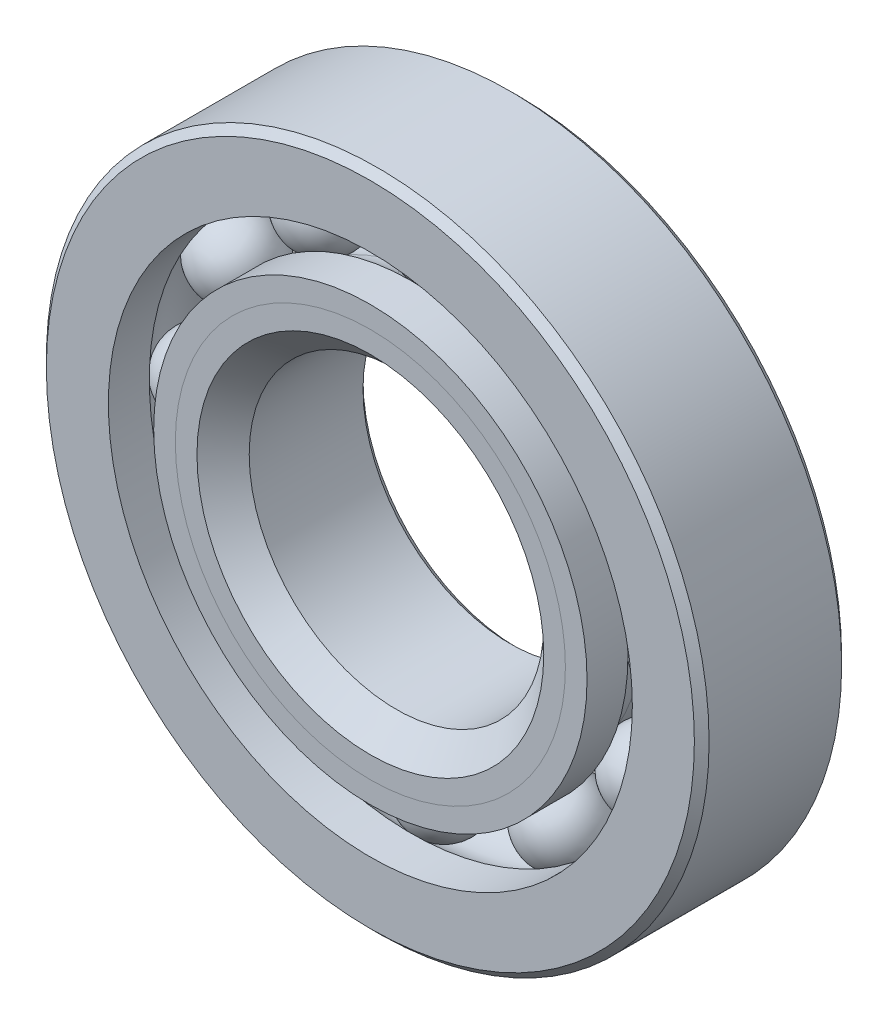
from build123d import *

# Parameters (mm, degrees)
CIRPATTERN1_COUNT = 12


with BuildPart() as part:
    # Sketch1 → Revolve1 (revolve)
    with BuildSketch(Plane(origin=(0, 0, 0), x_dir=(0, 0, -1), z_dir=(1, 0, 0))):
        with BuildLine():
            Line((2.8575, 14.2875), (-2.8575, 14.2875))
            Line((-2.8575, 14.2875), (-3.175, 13.97))
            Line((-3.175, 13.97), (-3.175, 11.295673077))
            Line((-3.175, 11.295673077), (-1.411111111, 11.295673077))
            ThreePointArc((-1.411111111, 11.295673077), (0, 12.035028901), (1.411111111, 11.295673077))
            Line((1.411111111, 11.295673077), (3.175, 11.295673077))
            Line((3.175, 11.295673077), (3.175, 13.97))
            Line((3.175, 13.97), (2.8575, 14.2875))
        make_face()
    revolve(axis=Axis((0, 0, 3.175), (0, 0, -1)))


with BuildPart() as body_2:
    # Sketch2 → Revolve2 (revolve)
    with BuildSketch(Plane(origin=(0, 0, 0), x_dir=(0, 0, -1), z_dir=(1, 0, 0))):
        with BuildLine():
            Line((-3.175, 9.341826923), (-1.411111111, 9.341826923))
            ThreePointArc((-1.411111111, 9.341826923), (-0.796536503, 8.798505656), (0, 8.602471099))
            Line((0, 8.602471099), (0, 7.476235549))
            Line((0, 7.476235549), (-2.242204313, 7.476235549))
            Line((-2.242204313, 7.476235549), (-3.175, 8.409031236))
            Line((-3.175, 8.409031236), (-3.175, 9.341826923))
        make_face()
    revolve(axis=Axis((0, 0, 3.175), (0, 0, -1)))


with BuildPart() as body_3:
    # Sketch3 → Revolve3 (revolve)
    with BuildSketch(Plane(origin=(0, 0, 0), x_dir=(0, 0, -1), z_dir=(1, 0, 0))):
        with BuildLine():
            Line((-3.175, 8.409031236), (-2.242204313, 7.476235549))
            Line((-2.242204313, 7.476235549), (0, 7.476235549))
            Line((0, 7.476235549), (0, 8.602471099))
            ThreePointArc((0, 8.602471099), (0.796536503, 8.798505656), (1.411111111, 9.341826923))
            Line((1.411111111, 9.341826923), (3.175, 9.341826923))
            Line((3.175, 9.341826923), (3.175, 6.6675))
            Line((3.175, 6.6675), (2.8575, 6.35))
            Line((2.8575, 6.35), (-2.048764451, 6.35))
            Line((-2.048764451, 6.35), (-3.175, 7.476235549))
            Line((-3.175, 7.476235549), (-3.175, 8.409031236))
        make_face()
    revolve(axis=Axis((0, 0, 3.175), (0, 0, -1)))


with BuildPart() as body_4:
    # Sketch4 → Revolve4 (revolve)
    with BuildSketch(Plane(origin=(0, 0, 0), x_dir=(0, 0, -1), z_dir=(1, 0, 0))):
        with BuildLine():
            Line((-1.716278901, 10.31875), (1.716278901, 10.31875))
            ThreePointArc((1.716278901, 10.31875), (0, 12.035028901), (-1.716278901, 10.31875))
        make_face()
    revolve(axis=Axis((0, 10.31875, 1.716278901), (0, 0, -1)))


with BuildPart() as cirpattern1_1:
    # CirPattern1: pattern copy
    add(body_4.part.rotate(Axis((0, 0, -3.175), (0, 0, 1)), 1 * 360 / CIRPATTERN1_COUNT))


with BuildPart() as cirpattern1_2:
    # CirPattern1: pattern copy
    add(body_4.part.rotate(Axis((0, 0, -3.175), (0, 0, 1)), 2 * 360 / CIRPATTERN1_COUNT))


with BuildPart() as cirpattern1_3:
    # CirPattern1: pattern copy
    add(body_4.part.rotate(Axis((0, 0, -3.175), (0, 0, 1)), 3 * 360 / CIRPATTERN1_COUNT))


with BuildPart() as cirpattern1_4:
    # CirPattern1: pattern copy
    add(body_4.part.rotate(Axis((0, 0, -3.175), (0, 0, 1)), 4 * 360 / CIRPATTERN1_COUNT))


with BuildPart() as cirpattern1_5:
    # CirPattern1: pattern copy
    add(body_4.part.rotate(Axis((0, 0, -3.175), (0, 0, 1)), 5 * 360 / CIRPATTERN1_COUNT))


with BuildPart() as cirpattern1_6:
    # CirPattern1: pattern copy
    add(body_4.part.rotate(Axis((0, 0, -3.175), (0, 0, 1)), 6 * 360 / CIRPATTERN1_COUNT))


with BuildPart() as cirpattern1_7:
    # CirPattern1: pattern copy
    add(body_4.part.rotate(Axis((0, 0, -3.175), (0, 0, 1)), 7 * 360 / CIRPATTERN1_COUNT))


with BuildPart() as cirpattern1_8:
    # CirPattern1: pattern copy
    add(body_4.part.rotate(Axis((0, 0, -3.175), (0, 0, 1)), 8 * 360 / CIRPATTERN1_COUNT))


with BuildPart() as cirpattern1_9:
    # CirPattern1: pattern copy
    add(body_4.part.rotate(Axis((0, 0, -3.175), (0, 0, 1)), 9 * 360 / CIRPATTERN1_COUNT))


with BuildPart() as cirpattern1_10:
    # CirPattern1: pattern copy
    add(body_4.part.rotate(Axis((0, 0, -3.175), (0, 0, 1)), 10 * 360 / CIRPATTERN1_COUNT))


with BuildPart() as cirpattern1_11:
    # CirPattern1: pattern copy
    add(body_4.part.rotate(Axis((0, 0, -3.175), (0, 0, 1)), 11 * 360 / CIRPATTERN1_COUNT))


solid = Compound([part.part, body_2.part, body_3.part, body_4.part, cirpattern1_1.part, cirpattern1_2.part, cirpattern1_3.part, cirpattern1_4.part, cirpattern1_5.part, cirpattern1_6.part, cirpattern1_7.part, cirpattern1_8.part, cirpattern1_9.part, cirpattern1_10.part, cirpattern1_11.part])
